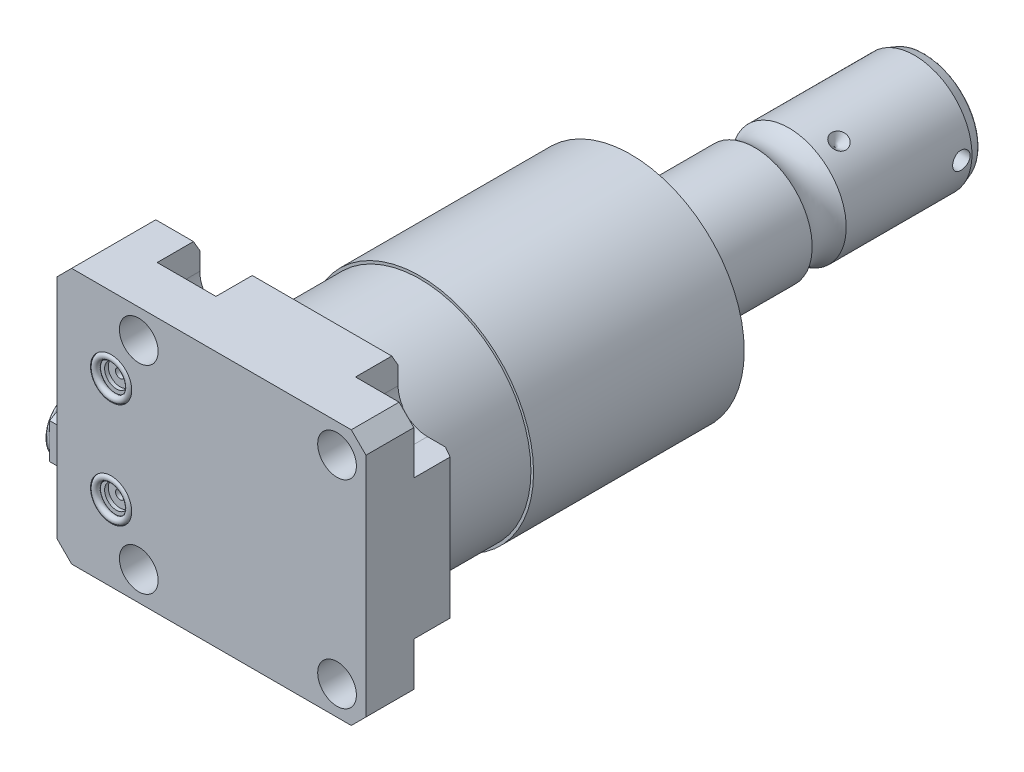
from build123d import *

# Parameters (mm, degrees)
SKETCH1_W          = 85.496
SKETCH1_H          = 70.866
EXTRUDE1_DEPTH     = 25.019
HOLE1_D            = 10.719
CUT_EXTRUDE2_DEPTH = 11.786
SKETCH6_R          = 5.7023
CUT_EXTRUDE3_DEPTH = 1.4478
SKETCH7_R          = 3.2512
CUT_EXTRUDE4_DEPTH = 1.016
SKETCH8_R          = 1.2446
CUT_EXTRUDE5_DEPTH = 11.9888
SKETCH9_R          = 0.9271
CHAMFER1_SIZE      = 4.064
CHAMFER2_SIZE      = 3.0226
CHAMFER2_SIZE2     = 1.745098924
SKETCH26_R         = 8.509
EXTRUDE2_DEPTH     = 7.87401575
FILLET1_R          = 1.01600203
EXTRUDE3_START     = -1.6002032
EXTRUDE3_DEPTH     = 5.00381001
SKETCH28_R         = 12.8269939
SKETCH28_R_2       = 12.5729934
CUT_EXTRUDE6_DEPTH = 0.3
CUT_EXTRUDE7_DEPTH = 8
CIRPATTERN1_COUNT  = 3
SKETCH31_W         = 3.81
SKETCH31_H         = 2.413
FILLET2_R          = 0.635


with BuildPart() as part:
    # Sketch1 → Extrude1 (new body)
    with BuildSketch(Plane.XY):
        with Locations((-7.315, 0)):
            Rectangle(SKETCH1_W, SKETCH1_H)
    extrude(amount=EXTRUDE1_DEPTH)

    # Hole1 (through all)
    with Locations(Plane(origin=(0, 0, 0), x_dir=(-1, 0, 0), z_dir=(0, 0, -1))):
        with Locations((-27.432, -27.432), (-27.432, 27.432), (27.432, 27.432), (27.432, -27.432)):
            Hole(HOLE1_D / 2)

    # Sketch3 → Cut-Extrude2 (cut)
    with BuildSketch(Plane(origin=(0, 0, 0), x_dir=(-1, 0, 0), z_dir=(0, 0, -1))):
        with BuildLine():
            Line((-27.432, -19.304), (-35.433, -19.304))
            Line((-35.433, -19.304), (-35.433, -35.433))
            Line((-35.433, -35.433), (-19.304, -35.433))
            Line((-19.304, -35.433), (-19.304, -27.432))
            ThreePointArc((-19.304, -27.432), (-21.684636083, -21.684636083), (-27.432, -19.304))
        make_face()
        with BuildLine():
            Line((-35.433, 19.304), (-35.433, 35.433))
            Line((-35.433, 35.433), (-19.304, 35.433))
            Line((-19.304, 35.433), (-19.304, 27.432))
            ThreePointArc((-19.304, 27.432), (-21.684636083, 21.684636083), (-27.432, 19.304))
            Line((-27.432, 19.304), (-35.433, 19.304))
        make_face()
        with BuildLine():
            Line((19.304, 35.433), (19.304, 27.432))
            ThreePointArc((19.304, 27.432), (27.432, 19.304), (35.56, 27.432))
            Line((35.56, 27.432), (35.56, 35.433))
            Line((35.56, 35.433), (19.304, 35.433))
        make_face()
        with BuildLine():
            Line((35.56, -35.433), (19.304, -35.433))
            Line((19.304, -35.433), (19.304, -27.432))
            ThreePointArc((19.304, -27.432), (27.432, -19.304), (35.56, -27.432))
            Line((35.56, -27.432), (35.56, -35.433))
        make_face()
    extrude(amount=-CUT_EXTRUDE2_DEPTH, mode=Mode.SUBTRACT)

    # Sketch23 → Cut-Revolve5 (revolve, cut)
    with BuildSketch(Plane.XY.offset(12.522), mode=Mode.PRIVATE) as cut_revolve5_sk:
        Polygon((-50.063, -23.749), (-49.809, -23.749), (-49.809, -19.6596), (-49.0978, -18.9484), (-35.6358, -18.9484), (-35.6358, -13.0048), (-50.063, -13.0048), align=None)
    cut_revolve5 = revolve(cut_revolve5_sk.sketch.rotate(Axis((-11.939660979, -13.0048, 12.522), (-1, 0, 0)), 180), axis=Axis((-11.939660979, -13.0048, 12.522), (-1, 0, 0)), mode=Mode.SUBTRACT)  # turned: the seam where the file's is

    # Mirror1: Cut-Revolve5 across plane
    add(cut_revolve5.mirror(Plane.ZX), mode=Mode.SUBTRACT)

    # Sketch6 → Cut-Extrude3 (cut)
    with BuildSketch(Plane.XY.offset(25.019)):
        with Locations((-35.077, -14.529)):
            Circle(SKETCH6_R)
        with Locations((-35.077, 14.529)):
            Circle(SKETCH6_R)
    extrude(amount=-CUT_EXTRUDE3_DEPTH, mode=Mode.SUBTRACT)

    # Sketch7 → Cut-Extrude4 (cut)
    with BuildSketch(Plane.XY.offset(23.5712)):
        with Locations((-35.077, 14.529)):
            Circle(SKETCH7_R)
        with Locations((-35.077, -14.529)):
            Circle(SKETCH7_R)
    extrude(amount=-CUT_EXTRUDE4_DEPTH, mode=Mode.SUBTRACT)

    # Sketch8 → Cut-Extrude5 (cut)
    with BuildSketch(Plane.XY.offset(22.5552)):
        with Locations((-35.077, 14.529)):
            Circle(SKETCH8_R)
        with Locations((-35.077, -14.529)):
            Circle(SKETCH8_R)
    extrude(amount=-CUT_EXTRUDE5_DEPTH, mode=Mode.SUBTRACT)

    # Chamfer1
    chamfer1_edges = [part.edges().sort_by_distance(p)[0] for p in [
        (-50.063, 35.433, 12.5095),
        (35.433, 35.433, 18.4025),
        (35.433, -35.433, 18.4025),
        (-50.063, -35.433, 12.5095),
    ]]
    chamfer(chamfer1_edges, length=CHAMFER1_SIZE)

    # Chamfer2
    chamfer2_edges = [part.edges().sort_by_distance(p)[0] for p in [
        (-40.7795, -35.433, 0),
        (35.433, 0, 0),
        (0, 35.433, 0),
        (-40.7795, 35.433, 0),
        (0, -35.433, 0),
    ]]
    chamfer2_side = [part.faces().sort_by_distance(p)[0] for p in [
        (-8.721219411, 0, 0),
    ]]
    chamfer(chamfer2_edges, length=CHAMFER2_SIZE, length2=CHAMFER2_SIZE2, reference=chamfer2_side[0])

    # Sketch24 → Revolve4 (revolve)
    with BuildSketch(Plane(origin=(0, 0, 0), x_dir=(0, 0, -1), z_dir=(1, 0, 0)), mode=Mode.PRIVATE) as revolve4_sk:
        Polygon((0, 0), (0, 30.658), (25.4, 30.658), (25.4, 31.3945), (83.687301194, 31.3945), (86.995, 19.05), (86.995, 0), align=None)
    revolve(revolve4_sk.sketch.rotate(Axis((0, 0, 0), (0, 0, -1)), 90), axis=Axis((0, 0, 0), (0, 0, -1)))  # turned: the seam where the file's is

    # Sketch17 → Revolve3 (revolve)
    with BuildSketch(Plane(origin=(0, 0, 0), x_dir=(0, 0, -1), z_dir=(1, 0, 0)), mode=Mode.PRIVATE) as revolve3_sk:
        with BuildLine():
            Line((86.995, 0), (86.995, -15.875))
            Line((86.995, -15.875), (118.000705156, -15.875))
            ThreePointArc((118.000705156, -15.875), (122.708, -14.3255), (127.415294844, -15.875))
            Line((127.415294844, -15.875), (162.205, -15.875))
            Line((162.205, -15.875), (165.126, -14.811842946))
            Line((165.126, -14.811842946), (165.126, 0))
            Line((165.126, 0), (86.995, 0))
        make_face()
    revolve(revolve3_sk.sketch.rotate(Axis((0, 0, -130.8989), (0, 0, 1)), 270), axis=Axis((0, 0, -130.8989), (0, 0, 1)))  # turned: the seam where the file's is

    # Sketch26 → Extrude2 (add)
    with BuildSketch(Plane.ZY.offset(49.809)):
        with Locations(Location((12.522, -13.0048, 0), (0, 0, 270))):  # turned: the seam where the file's is
            Circle(SKETCH26_R)
    extrude(amount=EXTRUDE2_DEPTH)

    # Fillet1
    fillet1_edges = [part.edges().sort_by_distance(p)[0] for p in [
        (-57.68301575, -4.4958, 12.522),
    ]]
    fillet(fillet1_edges, radius=FILLET1_R)

    # Sketch27 → Extrude3 (add)
    with BuildSketch(Plane.ZY.offset(57.68301575).offset(EXTRUDE3_START)):
        Polygon((4.013, -8.092126559), (4.013, -17.917473441), (12.522, -22.830146881), (21.031, -17.917473441), (21.031, -8.092126559), (12.522, -3.179453119), align=None)
    extrude(amount=-EXTRUDE3_DEPTH)

    # Sketch28 → Cut-Extrude6 (cut)
    with BuildSketch(Plane(origin=(0, 0, -165.126), x_dir=(-1, 0, 0), z_dir=(0, 0, -1))):
        Circle(SKETCH28_R)
        Circle(SKETCH28_R_2, mode=Mode.SUBTRACT)
    extrude(amount=-CUT_EXTRUDE6_DEPTH, mode=Mode.SUBTRACT)

    # Sketch29 → Cut-Extrude7 (cut)
    with BuildSketch(Plane(origin=(0, 0, -165.126), x_dir=(-1, 0, 0), z_dir=(0, 0, -1))):
        Polygon((4, -2.309401077), (4, 2.309401077), (0, 4.618802154), (-4, 2.309401077), (-4, -2.309401077), (0, -4.618802154), align=None)
    extrude(amount=-CUT_EXTRUDE7_DEPTH, mode=Mode.SUBTRACT)

    # Sketch30 → Cut-Revolve6 (revolve, cut)
    with BuildSketch(Plane(origin=(0, 0, 0), x_dir=(1, 0, 0), z_dir=(0, 1, 0)), mode=Mode.PRIVATE) as cut_revolve6_sk:
        Polygon((-15.875, 135.789), (-13.462, 133.376), (-15.875, 133.376), align=None)
    cut_revolve6 = revolve(cut_revolve6_sk.sketch.rotate(Axis((-27.819320819, 0, -133.376), (1, 0, 0)), 180), axis=Axis((-27.819320819, 0, -133.376), (1, 0, 0)), mode=Mode.SUBTRACT)  # turned: the seam where the file's is

    # CirPattern1: Cut-Revolve6 ×3 about axis
    cirpattern1_axis = Axis((0, 0, -130.8989), (0, 0, -1))
    for i in range(1, CIRPATTERN1_COUNT):
        add(cut_revolve6.rotate(cirpattern1_axis, i * 360 / CIRPATTERN1_COUNT), mode=Mode.SUBTRACT)

    # Sketch31 → Cut-Revolve7 (revolve, cut)
    with BuildSketch(Plane(origin=(0, 0, 0), x_dir=(1, 0, 0), z_dir=(0, 1, 0)), mode=Mode.PRIVATE) as cut_revolve7_sk:
        with Locations((13.97, 160.4905)):
            Rectangle(SKETCH31_W, SKETCH31_H)
    revolve(cut_revolve7_sk.sketch.rotate(Axis((-9.187915639, 0, -159.284), (1, 0, 0)), 180), axis=Axis((-9.187915639, 0, -159.284), (1, 0, 0)), mode=Mode.SUBTRACT)  # turned: the seam where the file's is

    # Fillet2
    fillet2_edges = [part.edges().sort_by_distance(p)[0] for p in [
        (14.811842946, 0, -165.126),
    ]]
    fillet(fillet2_edges, radius=FILLET2_R)


with BuildPart() as body_2:
    # Sketch9 → Revolve1 (revolve)
    with BuildSketch(Plane(origin=(-41.656, 14.5288, 23.5712), x_dir=(1, 0, 0), z_dir=(0, 1, 0))):
        with Locations((11.3542, -0.9271)):
            Circle(SKETCH9_R)
    revolve(axis=Axis((-35.077, 14.5288, 25.51811), (0, 0, -1)))


with BuildPart() as body_3:
    # Mirror2: mirrored copy
    add(body_2.part.mirror(Plane.ZX))


solid = Compound([part.part, body_2.part, body_3.part])
